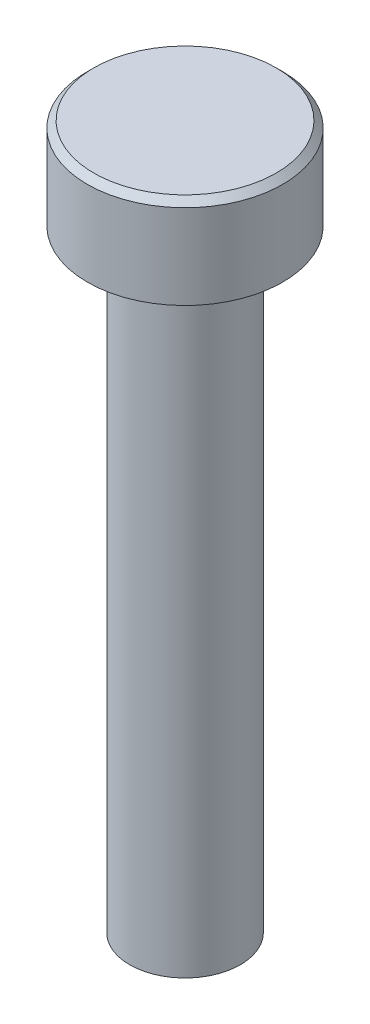
from build123d import *

# Parameters (mm, degrees)
CHAMFER_1_SIZE = 1


with BuildPart() as part:
    # Эскиз1 → Повернуть1 (revolve)
    with BuildSketch(Plane.XY):
        Polygon((0, 0), (0, 108), (15, 108), (15, 94), (8.5, 94), (8.5, 0), align=None)
    revolve(axis=Axis((0, 0, 0), (0, -1, 0)))

    # Фаска1
    chamfer_1_edges = [part.edges().sort_by_distance(p)[0] for p in [
        (-15, 108, 0),
    ]]
    chamfer(chamfer_1_edges, length=CHAMFER_1_SIZE)


solid = part.part
